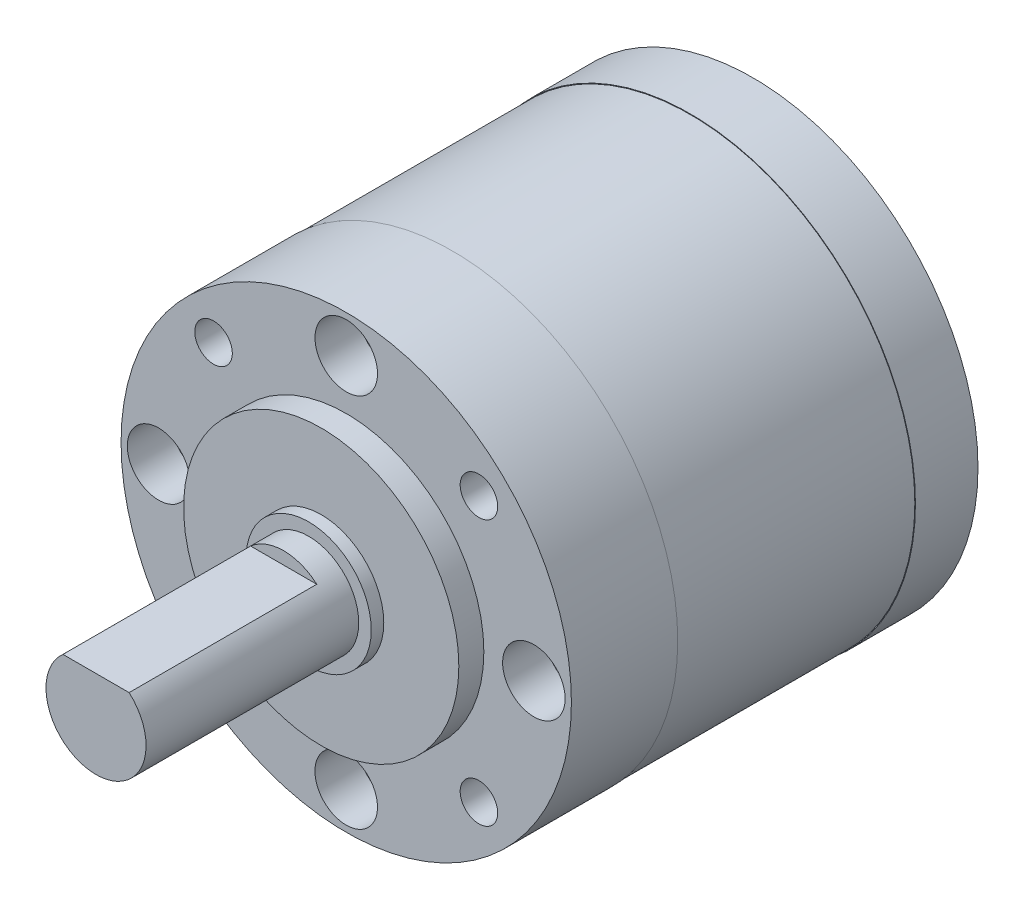
from build123d import *

# Parameters (mm, degrees)
SKETCH_1_R               = 18
EXTRUDE_1_DEPTH          = 8.5
SKETCH_2_R               = 17.95
EXTRUDE_2_DEPTH          = 19
SKETCH_3_R               = 18
EXTRUDE_3_DEPTH          = 5
SKETCH_4_R               = 11
EXTRUDE_4_DEPTH          = 2
SKETCH_5_R               = 5
EXTRUDE_5_DEPTH          = 1
SKETCH_6_R               = 4
EXTRUDE_6_DEPTH          = 17
CUT_EXTRUDE_1_DEPTH      = 1
CUT_EXTRUDE_1_DEPTH_BACK = 15
SKETCH_8_R               = 11
CUT_EXTRUDE_2_DEPTH      = 4
SKETCH_9_R               = 4
CUT_EXTRUDE_3_DEPTH      = 17
SKETCH_10_R              = 1.5
CUT_EXTRUDE_4_DEPTH      = 10
PATTERN_CIRCULAR_1_COUNT = 8
SKETCH_11_R              = 2.5
CUT_EXTRUDE_5_DEPTH      = 3.5
PATTERN_CIRCULAR_2_COUNT = 4


with BuildPart() as part:
    # 草圖1 → 填料-伸長1 (new body)
    with BuildSketch(Plane.XY):
        Circle(SKETCH_1_R)
    extrude(amount=EXTRUDE_1_DEPTH)

    # 草圖2 → 填料-伸長2 (add)
    with BuildSketch(Plane(origin=(0, 0, 0), x_dir=(-1, 0, 0), z_dir=(0, 0, -1))):
        Circle(SKETCH_2_R)
    extrude(amount=EXTRUDE_2_DEPTH)

    # 草圖3 → 填料-伸長3 (add)
    with BuildSketch(Plane(origin=(0, 0, -19), x_dir=(-1, 0, 0), z_dir=(0, 0, -1))):
        Circle(SKETCH_3_R)
    extrude(amount=EXTRUDE_3_DEPTH)

    # 草圖4 → 填料-伸長4 (add)
    with BuildSketch(Plane.XY.offset(8.5)):
        Circle(SKETCH_4_R)
    extrude(amount=EXTRUDE_4_DEPTH)

    # 草圖5 → 填料-伸長5 (add)
    with BuildSketch(Plane.XY.offset(10.5)):
        Circle(SKETCH_5_R)
    extrude(amount=EXTRUDE_5_DEPTH)

    # 草圖6 → 填料-伸長6 (add)
    with BuildSketch(Plane.XY.offset(11.5)):
        Circle(SKETCH_6_R)
    extrude(amount=EXTRUDE_6_DEPTH)

    # 草圖7 → 除料-伸長1 (cut, two sides)
    with BuildSketch(Plane.XY.offset(28.5)) as cut_extrude_1_sk:
        Polygon((-71.543868334, 3), (-2.645751311, 3), (2.645751311, 3), (71.543868334, 3), (71.543868334, 140.796234045), (-71.543868334, 140.796234045), align=None)
    extrude(amount=CUT_EXTRUDE_1_DEPTH, mode=Mode.SUBTRACT)
    extrude(cut_extrude_1_sk.sketch, amount=-CUT_EXTRUDE_1_DEPTH_BACK, mode=Mode.SUBTRACT)

    # 草圖8 → 除料-伸長2 (cut)
    with BuildSketch(Plane(origin=(0, 0, -24), x_dir=(-1, 0, 0), z_dir=(0, 0, -1))):
        Circle(SKETCH_8_R)
    extrude(amount=-CUT_EXTRUDE_2_DEPTH, mode=Mode.SUBTRACT)

    # 草圖9 → 除料-伸長3 (cut)
    with BuildSketch(Plane(origin=(0, 0, -24), x_dir=(-1, 0, 0), z_dir=(0, 0, -1))):
        Circle(SKETCH_9_R)
    extrude(amount=-CUT_EXTRUDE_3_DEPTH, mode=Mode.SUBTRACT)

    # 草圖10 → 除料-伸長4 (cut)
    with BuildSketch(Plane.XY.offset(8.5)):
        with Locations((0, 15)):
            Circle(SKETCH_10_R)
    cut_extrude_4 = extrude(amount=-CUT_EXTRUDE_4_DEPTH, mode=Mode.SUBTRACT)

    # 環狀複製排列1: 除料-伸長4 ×8 about axis
    pattern_circular_1_axis = Axis((0, 0, 0), (0, 0, 1))
    for i in range(1, PATTERN_CIRCULAR_1_COUNT):
        add(cut_extrude_4.rotate(pattern_circular_1_axis, i * 360 / PATTERN_CIRCULAR_1_COUNT), mode=Mode.SUBTRACT)

    # 草圖11 → 除料-伸長5 (cut)
    with BuildSketch(Plane.XY.offset(8.5)):
        with Locations((0, 15)):
            Circle(SKETCH_11_R)
    cut_extrude_5 = extrude(amount=-CUT_EXTRUDE_5_DEPTH, mode=Mode.SUBTRACT)

    # 環狀複製排列2: 除料-伸長5 ×4 about axis
    pattern_circular_2_axis = Axis((0, 0, 0), (0, 0, 1))
    for i in range(1, PATTERN_CIRCULAR_2_COUNT):
        add(cut_extrude_5.rotate(pattern_circular_2_axis, i * 360 / PATTERN_CIRCULAR_2_COUNT), mode=Mode.SUBTRACT)


solid = part.part
